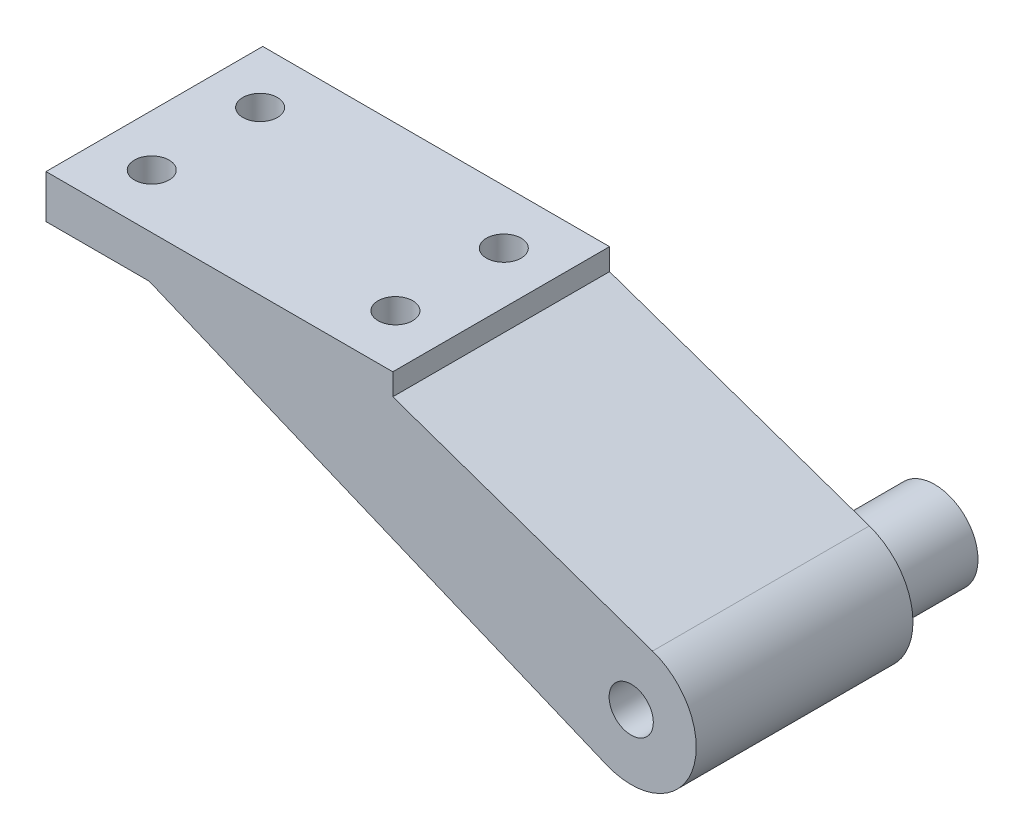
from build123d import *

# Parameters (mm, degrees)
SKETCH1_W           = 50.8
SKETCH1_H           = 31.75
BOSS_EXTRUDE1_DEPTH = 6.35
SKETCH2_R           = 9.525
SKETCH2_R_2         = 3.2385
BOSS_EXTRUDE2_DEPTH = 31.75
BOSS_EXTRUDE3_DEPTH = 31.75
CUT_EXTRUDE1_REACH  = 8.35
SKETCH5_R           = 2.54
SKETCH6_R           = 2.54
CUT_EXTRUDE2_DEPTH  = 35.925
SKETCH7_R           = 4.7625
CUT_EXTRUDE3_DEPTH  = 19.05
SKETCH4_R           = 6.35
SKETCH4_R_2         = 3.2385
BOSS_EXTRUDE4_DEPTH = 12.7


with BuildPart() as part:
    # Sketch1 → Boss-Extrude1 (new body)
    with BuildSketch(Plane(origin=(0, 0, 0), x_dir=(1, 0, 0), z_dir=(0, 1, 0))):
        with Locations((25.4, 15.875)):
            Rectangle(SKETCH1_W, SKETCH1_H)
    extrude(amount=BOSS_EXTRUDE1_DEPTH)



with BuildPart() as body_2:
    # Sketch2 → Boss-Extrude2 (new body)
    with BuildSketch(Plane.XY):
        with Locations((85.725, -19.05)):
            Circle(SKETCH2_R)
        with Locations((85.725, -19.05)):
            Circle(SKETCH2_R_2, mode=Mode.SUBTRACT)
    extrude(amount=-BOSS_EXTRUDE2_DEPTH)


with BuildPart() as part_1:
    add(part.part)

    add(body_2.part)  # Boss-Extrude3 merges body 2
    # Sketch3 → Boss-Extrude3 (add)
    with BuildSketch(Plane.XY):
        with BuildLine():
            Line((50.8, 3.175), (88.852564162, -10.05311346))
            ThreePointArc((88.852564162, -10.05311346), (76.82515217, -15.656132943), (82.067835176, -27.844928678))
            Line((82.067835176, -27.844928678), (15.104990042, 0))
            Line((15.104990042, 0), (15.104990042, 3.175))
            Line((15.104990042, 3.175), (50.8, 3.175))
        make_face()
    extrude(amount=-BOSS_EXTRUDE3_DEPTH)

    # Sketch5 → Cut-Extrude1 (cut, up to next)
    with BuildSketch(Plane.XZ, mode=Mode.PRIVATE) as cut_extrude1_sk1:
        with Locations((7.552495021, -7.9375)):
            Circle(SKETCH5_R)
    cut_extrude1_tool1 = extrude(cut_extrude1_sk1.sketch, amount=-CUT_EXTRUDE1_REACH, mode=Mode.PRIVATE) & part_1.part
    add(cut_extrude1_tool1.solids().sort_by_distance((7.552495, 0, -7.9375))[0], mode=Mode.SUBTRACT)
    # Sketch5 → Cut-Extrude1 (cut, up to next)
    with BuildSketch(Plane.XZ, mode=Mode.PRIVATE) as cut_extrude1_sk2:
        with Locations((7.552495021, -23.8125)):
            Circle(SKETCH5_R)
    cut_extrude1_tool2 = extrude(cut_extrude1_sk2.sketch, amount=-CUT_EXTRUDE1_REACH, mode=Mode.PRIVATE) & part_1.part
    add(cut_extrude1_tool2.solids().sort_by_distance((7.552495, 0, -23.8125))[0], mode=Mode.SUBTRACT)

    # Sketch6 → Cut-Extrude2 (cut, through all)
    with BuildSketch(Plane(origin=(0, 6.35, 0), x_dir=(1, 0, 0), z_dir=(0, 1, 0))):
        with Locations((43.247504979, 7.9375)):
            Circle(SKETCH6_R)
        with Locations((43.247504979, 23.8125)):
            Circle(SKETCH6_R)
    extrude(amount=-CUT_EXTRUDE2_DEPTH, mode=Mode.SUBTRACT)

    # Sketch7 → Cut-Extrude3 (cut)
    with BuildSketch(Plane(origin=(0, -19.05, 0), x_dir=(1, 0, 0), z_dir=(0, 1, 0))):
        with Locations((43.247504979, 23.8125)):
            Circle(SKETCH7_R)
        with Locations((43.247504979, 7.9375)):
            Circle(SKETCH7_R)
    extrude(amount=CUT_EXTRUDE3_DEPTH, mode=Mode.SUBTRACT)

    # Sketch4 → Boss-Extrude4 (add)
    with BuildSketch(Plane.XY.offset(-31.75)):
        with Locations((85.725, -19.05)):
            Circle(SKETCH4_R)
        with Locations((85.725, -19.05)):
            Circle(SKETCH4_R_2, mode=Mode.SUBTRACT)
    extrude(amount=-BOSS_EXTRUDE4_DEPTH)


solid = part_1.part
